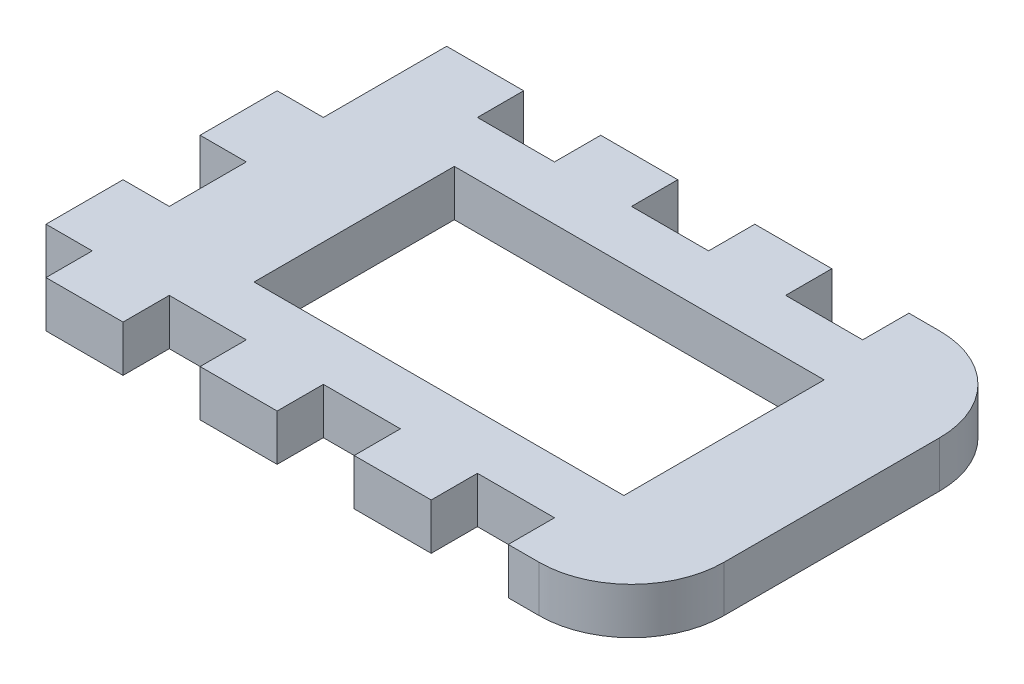
from build123d import *

# Parameters (mm, degrees)
SKETCH1_W           = 38
SKETCH1_H           = 26
BOSS_EXTRUDE1_DEPTH = 1.5
SKETCH2_W           = 24
SKETCH2_H           = 13
CUT_EXTRUDE1_DEPTH  = 3
SKETCH8_W           = 5
SKETCH8_H           = 3
BOSS_EXTRUDE2_DEPTH = 3
SKETCH9_W           = 5
SKETCH9_H           = 3
CUT_EXTRUDE2_DEPTH  = 3
FILLET1_R           = 6


with BuildPart() as part:
    # Sketch1 → Boss-Extrude1 (new body, symmetric)
    with BuildSketch(Plane(origin=(0, 0, 0), x_dir=(1, 0, 0), z_dir=(0, 1, 0))):
        Rectangle(SKETCH1_W, SKETCH1_H)
    extrude(amount=BOSS_EXTRUDE1_DEPTH, both=True)

    # Sketch2 → Cut-Extrude1 (cut)
    with BuildSketch(Plane.XZ.offset(1.5)):
        Rectangle(SKETCH2_W, SKETCH2_H)
    extrude(amount=-CUT_EXTRUDE1_DEPTH, mode=Mode.SUBTRACT)

    # Sketch8 → Boss-Extrude2 (add)
    with BuildSketch(Plane.ZY.offset(19)):
        with Locations((-2.5, 0)):
            Rectangle(SKETCH8_W, SKETCH8_H)
        with Locations((7.5, 0)):
            Rectangle(SKETCH8_W, SKETCH8_H)
    extrude(amount=BOSS_EXTRUDE2_DEPTH)

    # Sketch9 → Cut-Extrude2 (cut)
    with BuildSketch(Plane.XZ.offset(1.5)):
        with Locations((-11.5, -11.5)):
            Rectangle(SKETCH9_W, SKETCH9_H)
        with Locations((-11.5, 11.5)):
            Rectangle(SKETCH9_W, SKETCH9_H)
        with Locations((-1.5, -11.5)):
            Rectangle(SKETCH9_W, SKETCH9_H)
        with Locations((-1.5, 11.5)):
            Rectangle(SKETCH9_W, SKETCH9_H)
        with Locations((8.5, -11.5)):
            Rectangle(SKETCH9_W, SKETCH9_H)
        with Locations((8.5, 11.5)):
            Rectangle(SKETCH9_W, SKETCH9_H)
    extrude(amount=-CUT_EXTRUDE2_DEPTH, mode=Mode.SUBTRACT)

    # Fillet1
    fillet1_edges = [part.edges().sort_by_distance(p)[0] for p in [
        (19, 0, 13),
        (19, 0, -13),
    ]]
    fillet(fillet1_edges, radius=FILLET1_R)


solid = part.part
